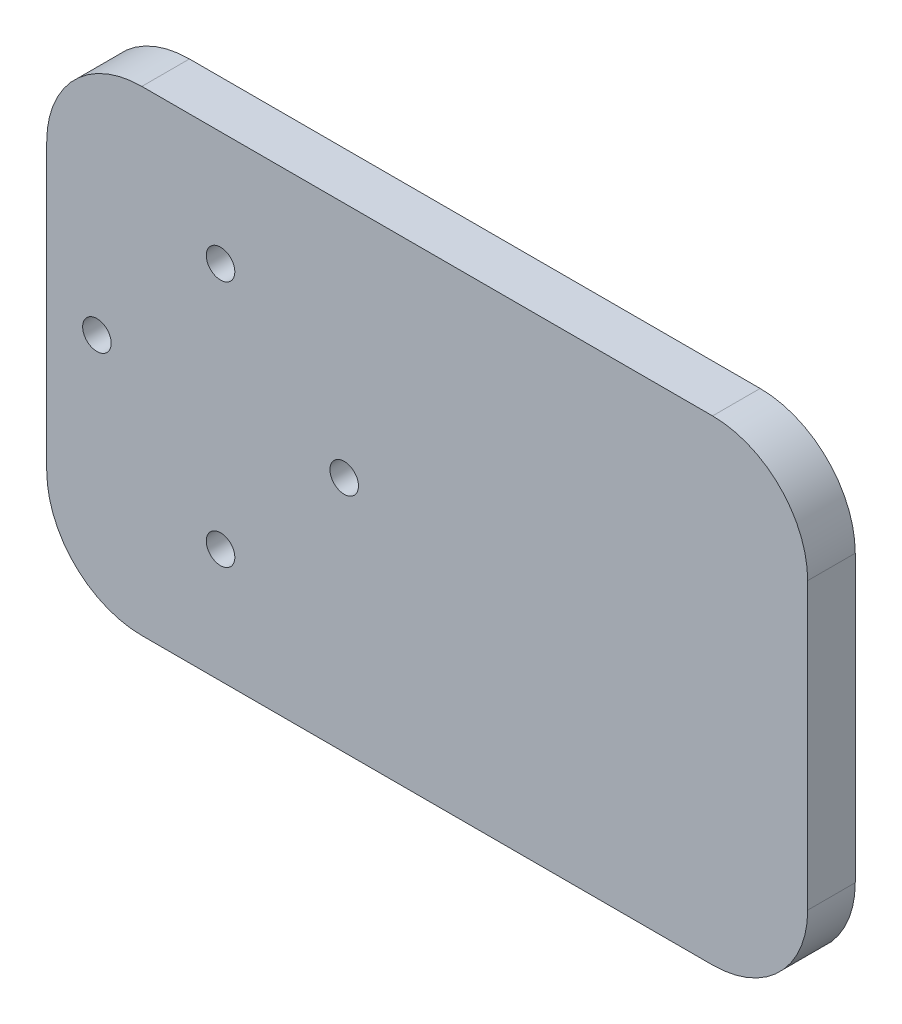
from build123d import *

# Parameters (mm, degrees)
SKETCH1_W           = 80
SKETCH1_H           = 50
BOSS_EXTRUDE1_DEPTH = 5
SKETCH2_R           = 1.5
CUT_EXTRUDE1_DEPTH  = 5
FILLET2_R           = 10


with BuildPart() as part:
    # Sketch1 → Boss-Extrude1 (new body)
    with BuildSketch(Plane.XY):
        Rectangle(SKETCH1_W, SKETCH1_H)
    extrude(amount=BOSS_EXTRUDE1_DEPTH)

    # Sketch2 → Cut-Extrude1 (cut)
    with BuildSketch(Plane.XY.offset(5)):
        with Locations((-21.727182294, 13)):
            Circle(SKETCH2_R)
        with Locations((-8.727182294, 0)):
            Circle(SKETCH2_R)
        with Locations((-21.727182294, -13)):
            Circle(SKETCH2_R)
        with Locations((-34.727182294, 0)):
            Circle(SKETCH2_R)
    extrude(amount=-CUT_EXTRUDE1_DEPTH, mode=Mode.SUBTRACT)

    # Fillet2
    fillet2_edges = [part.edges().sort_by_distance(p)[0] for p in [
        (40, -25, 2.5),
        (-40, -25, 2.5),
        (-40, 25, 2.5),
        (40, 25, 2.5),
    ]]
    fillet(fillet2_edges, radius=FILLET2_R)


solid = part.part
